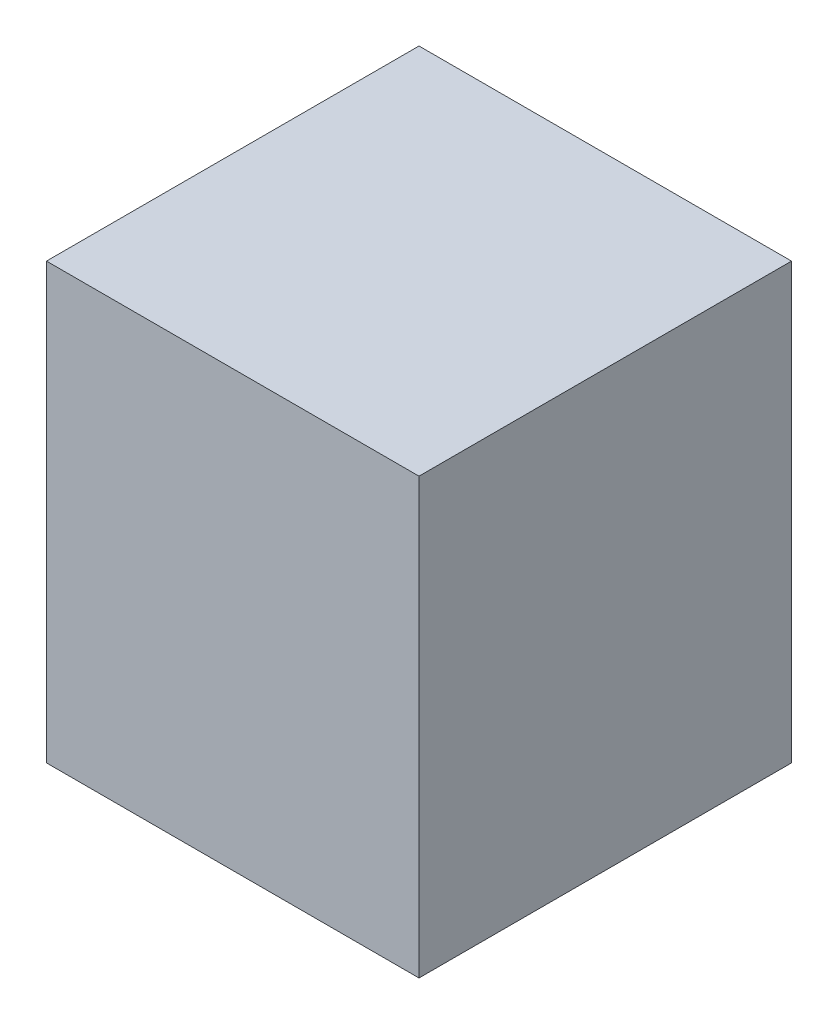
from build123d import *

# Parameters (mm, degrees)
SKETCH_1_W      = 300
SKETCH_1_H      = 300
EXTRUDE_1_DEPTH = 350


with BuildPart() as part:
    # 草图1 → 凸台-拉伸1 (new body)
    with BuildSketch(Plane(origin=(0, 0, 0), x_dir=(1, 0, 0), z_dir=(0, 1, 0))):
        Rectangle(SKETCH_1_W, SKETCH_1_H)
    extrude(amount=EXTRUDE_1_DEPTH)


solid = part.part
